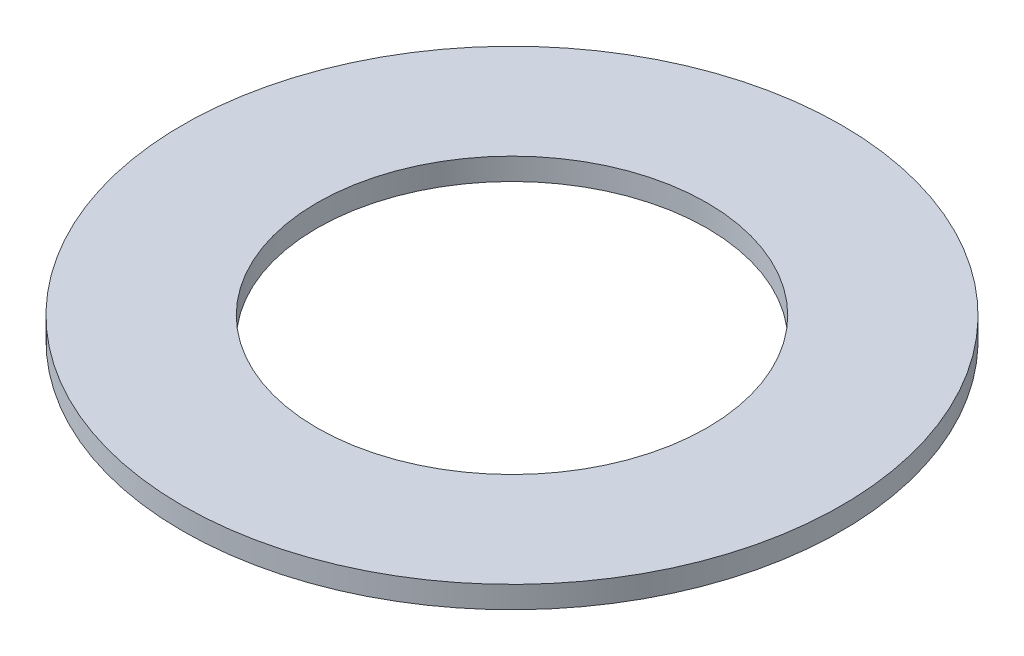
from build123d import *

# Parameters (mm, degrees)
SKETCH1_R           = 6
SKETCH1_R_2         = 3.55
BOSS_EXTRUDE1_DEPTH = 0.4


with BuildPart() as part:
    # Sketch1 → Boss-Extrude1 (new body)
    with BuildSketch(Plane(origin=(0, 0, 0), x_dir=(1, 0, 0), z_dir=(0, 1, 0))):
        Circle(SKETCH1_R)
        Circle(SKETCH1_R_2, mode=Mode.SUBTRACT)
    extrude(amount=BOSS_EXTRUDE1_DEPTH)


solid = part.part
